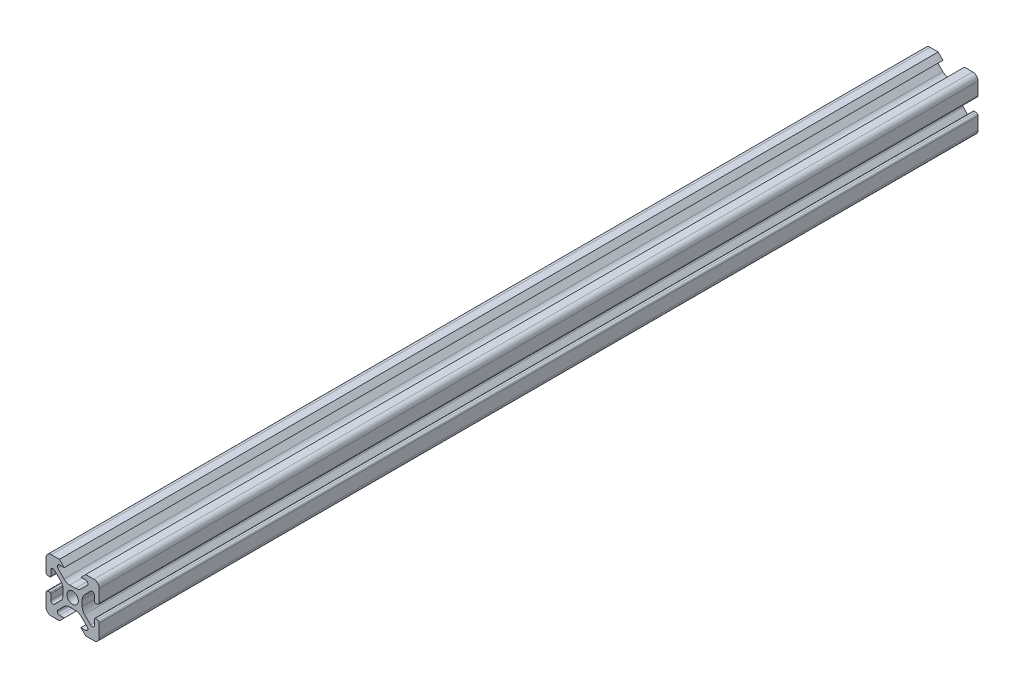
from build123d import *

# Parameters (mm, degrees)
SKETCH3_R           = 2.15
BOSS_EXTRUDE1_DEPTH = 330.2
CUT_EXTRUDE1_DEPTH  = 331.2


with BuildPart() as part:
    # Sketch3 → Boss-Extrude1 (new body)
    with BuildSketch(Plane.XY):
        with BuildLine():
            Line((3.2874, 10), (8, 10))
            ThreePointArc((8, 10), (9.414213562, 9.414213562), (10, 8))
            Line((10, 8), (10, 3.2874))
            ThreePointArc((10, 3.2874), (9.76937588, 2.73062412), (9.2126, 2.5))
            Line((9.2126, 2.5), (8.5048, 2.5))
            ThreePointArc((8.5048, 2.5), (8.289273853, 2.589273853), (8.2, 2.8048))
            Line((8.2, 2.8048), (8.2, 4.9118))
            ThreePointArc((8.2, 4.9118), (7.682565253, 5.686195824), (6.769103096, 5.504496904))
            Line((6.769103096, 5.504496904), (4.478679656, 3.214073464))
            ThreePointArc((4.478679656, 3.214073464), (3.828361402, 2.240803418), (3.6, 1.092753121))
            Line((3.6, 1.092753121), (3.6, -1.092753121))
            ThreePointArc((3.6, -1.092753121), (3.828361402, -2.240803418), (4.478679656, -3.214073464))
            Line((4.478679656, -3.214073464), (6.769103096, -5.504496904))
            ThreePointArc((6.769103096, -5.504496904), (7.682565253, -5.686195824), (8.2, -4.9118))
            Line((8.2, -4.9118), (8.2, -2.8048))
            ThreePointArc((8.2, -2.8048), (8.289273853, -2.589273853), (8.5048, -2.5))
            Line((8.5048, -2.5), (9.2126, -2.5))
            ThreePointArc((9.2126, -2.5), (9.76937588, -2.73062412), (10, -3.2874))
            Line((10, -3.2874), (10, -8))
            ThreePointArc((10, -8), (9.414213562, -9.414213562), (8, -10))
            Line((8, -10), (3.2874, -10))
            ThreePointArc((3.2874, -10), (2.73062412, -9.76937588), (2.5, -9.2126))
            Line((2.5, -9.2126), (2.5, -8.5048))
            ThreePointArc((2.5, -8.5048), (2.589273853, -8.289273853), (2.8048, -8.2))
            Line((2.8048, -8.2), (4.9118, -8.2))
            ThreePointArc((4.9118, -8.2), (5.686195824, -7.682565253), (5.504496904, -6.769103096))
            Line((5.504496904, -6.769103096), (3.214073464, -4.478679656))
            ThreePointArc((3.214073464, -4.478679656), (2.240803418, -3.828361402), (1.092753121, -3.6))
            Line((1.092753121, -3.6), (-1.092753121, -3.6))
            ThreePointArc((-1.092753121, -3.6), (-2.240803418, -3.828361402), (-3.214073464, -4.478679656))
            Line((-3.214073464, -4.478679656), (-5.504496904, -6.769103096))
            ThreePointArc((-5.504496904, -6.769103096), (-5.686195824, -7.682565253), (-4.9118, -8.2))
            Line((-4.9118, -8.2), (-2.8048, -8.2))
            ThreePointArc((-2.8048, -8.2), (-2.589273853, -8.289273853), (-2.5, -8.5048))
            Line((-2.5, -8.5048), (-2.5, -9.2126))
            ThreePointArc((-2.5, -9.2126), (-2.73062412, -9.76937588), (-3.2874, -10))
            Line((-3.2874, -10), (-8, -10))
            ThreePointArc((-8, -10), (-9.414213562, -9.414213562), (-10, -8))
            Line((-10, -8), (-10, -3.2874))
            ThreePointArc((-10, -3.2874), (-9.76937588, -2.73062412), (-9.2126, -2.5))
            Line((-9.2126, -2.5), (-8.5048, -2.5))
            ThreePointArc((-8.5048, -2.5), (-8.289273853, -2.589273853), (-8.2, -2.8048))
            Line((-8.2, -2.8048), (-8.2, -4.9118))
            ThreePointArc((-8.2, -4.9118), (-7.682565253, -5.686195824), (-6.769103096, -5.504496904))
            Line((-6.769103096, -5.504496904), (-4.478679656, -3.214073464))
            ThreePointArc((-4.478679656, -3.214073464), (-3.828361402, -2.240803418), (-3.6, -1.092753121))
            Line((-3.6, -1.092753121), (-3.6, 1.092753121))
            ThreePointArc((-3.6, 1.092753121), (-3.828361402, 2.240803418), (-4.478679656, 3.214073464))
            Line((-4.478679656, 3.214073464), (-6.769103096, 5.504496904))
            ThreePointArc((-6.769103096, 5.504496904), (-7.682565253, 5.686195824), (-8.2, 4.9118))
            Line((-8.2, 4.9118), (-8.2, 2.8048))
            ThreePointArc((-8.2, 2.8048), (-8.289273853, 2.589273853), (-8.5048, 2.5))
            Line((-8.5048, 2.5), (-9.2126, 2.5))
            ThreePointArc((-9.2126, 2.5), (-9.76937588, 2.73062412), (-10, 3.2874))
            Line((-10, 3.2874), (-10, 8))
            ThreePointArc((-10, 8), (-9.414213562, 9.414213562), (-8, 10))
            Line((-8, 10), (-3.2874, 10))
            ThreePointArc((-3.2874, 10), (-2.73062412, 9.76937588), (-2.5, 9.2126))
            Line((-2.5, 9.2126), (-2.5, 8.5048))
            ThreePointArc((-2.5, 8.5048), (-2.589273853, 8.289273853), (-2.8048, 8.2))
            Line((-2.8048, 8.2), (-4.9118, 8.2))
            ThreePointArc((-4.9118, 8.2), (-5.686195824, 7.682565253), (-5.504496904, 6.769103096))
            Line((-5.504496904, 6.769103096), (-3.214073464, 4.478679656))
            ThreePointArc((-3.214073464, 4.478679656), (-2.240803418, 3.828361402), (-1.092753121, 3.6))
            Line((-1.092753121, 3.6), (1.092753121, 3.6))
            ThreePointArc((1.092753121, 3.6), (2.240803418, 3.828361402), (3.214073464, 4.478679656))
            Line((3.214073464, 4.478679656), (5.504496904, 6.769103096))
            ThreePointArc((5.504496904, 6.769103096), (5.686195824, 7.682565253), (4.9118, 8.2))
            Line((4.9118, 8.2), (2.8048, 8.2))
            ThreePointArc((2.8048, 8.2), (2.589273853, 8.289273853), (2.5, 8.5048))
            Line((2.5, 8.5048), (2.5, 9.2126))
            ThreePointArc((2.5, 9.2126), (2.73062412, 9.76937588), (3.2874, 10))
        make_face()
        Circle(SKETCH3_R, mode=Mode.SUBTRACT)
    extrude(amount=BOSS_EXTRUDE1_DEPTH)

    # Sketch4 → Cut-Extrude1 (cut, through all)
    with BuildSketch(Plane.XY.offset(330.2)):
        Polygon((-6.018693607, 11.065698556), (-2.018693607, 7.065698556), (1.981306393, 7.065698556), (5.981306393, 11.065698556), align=None)
        Polygon((1.981306393, -7.065698556), (5.981306393, -11.065698556), (-6.018693607, -11.065698556), (-2.018693607, -7.065698556), align=None)
    extrude(amount=-CUT_EXTRUDE1_DEPTH, mode=Mode.SUBTRACT)


solid = part.part
